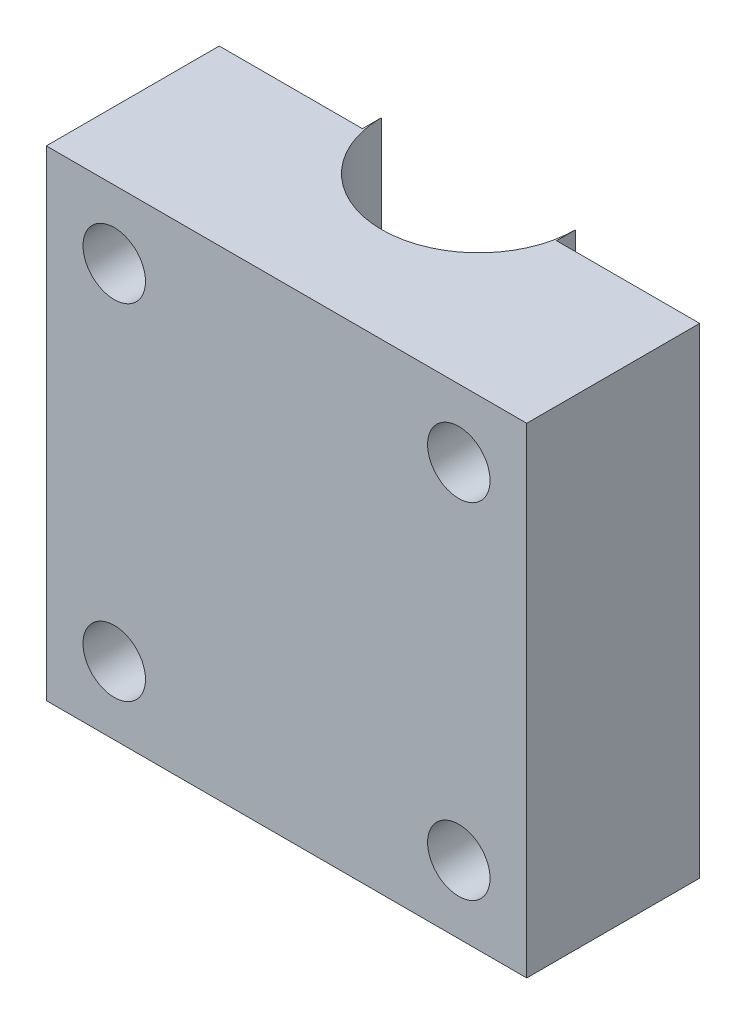
from build123d import *

# Parameters (mm, degrees)
SKETCH1_W           = 25
SKETCH1_H           = 25
BOSS_EXTRUDE2_DEPTH = 10
SKETCH2_R           = 5.05
CUT_EXTRUDE1_DEPTH  = 26
SKETCH3_R           = 1.625
CUT_EXTRUDE2_DEPTH  = 11
SKETCH4_W           = 7.45
SKETCH4_H           = 25
CUT_EXTRUDE3_DEPTH  = 1


with BuildPart() as part:
    # Sketch1 → Boss-Extrude2 (new body)
    with BuildSketch(Plane.XY):
        Rectangle(SKETCH1_W, SKETCH1_H)
    extrude(amount=BOSS_EXTRUDE2_DEPTH)

    # Sketch2 → Cut-Extrude1 (cut, through all)
    with BuildSketch(Plane(origin=(0, 12.5, 0), x_dir=(1, 0, 0), z_dir=(0, 1, 0))):
        Circle(SKETCH2_R)
    extrude(amount=-CUT_EXTRUDE1_DEPTH, mode=Mode.SUBTRACT)

    # Sketch3 → Cut-Extrude2 (cut, through all)
    with BuildSketch(Plane.XY.offset(10)):
        with Locations((-8.964466094, 8.964466094)):
            Circle(SKETCH3_R)
        with Locations((8.964466094, 8.964466094)):
            Circle(SKETCH3_R)
        with Locations((8.964466094, -8.964466094)):
            Circle(SKETCH3_R)
        with Locations((-8.964466094, -8.964466094)):
            Circle(SKETCH3_R)
    extrude(amount=-CUT_EXTRUDE2_DEPTH, mode=Mode.SUBTRACT)

    # Sketch4 → Cut-Extrude3 (cut)
    with BuildSketch(Plane(origin=(0, 0, 0), x_dir=(-1, 0, 0), z_dir=(0, 0, -1))):
        with Locations((-8.775, 0)):
            Rectangle(SKETCH4_W, SKETCH4_H)
        with Locations((8.775, 0)):
            Rectangle(SKETCH4_W, SKETCH4_H)
    extrude(amount=-CUT_EXTRUDE3_DEPTH, mode=Mode.SUBTRACT)


solid = part.part
